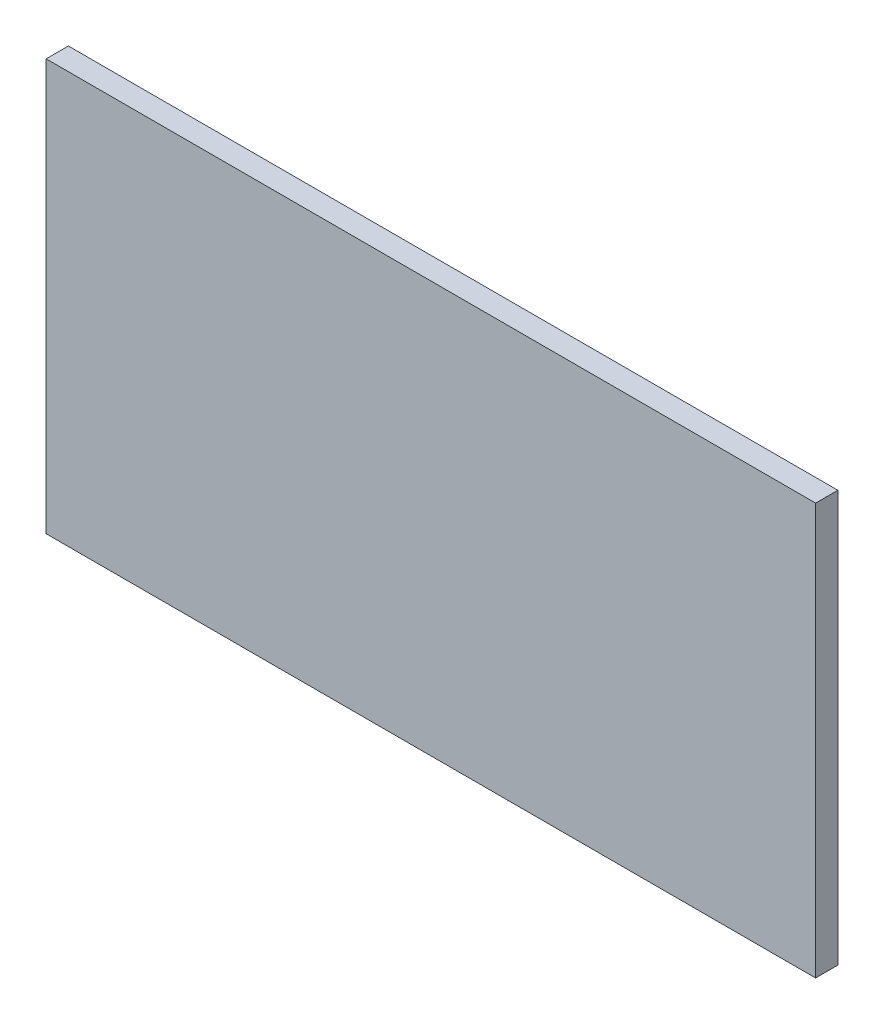
from build123d import *

# Parameters (mm, degrees)
SKETCH1_W           = 623
SKETCH1_H           = 333
BOSS_EXTRUDE1_DEPTH = 18


with BuildPart() as part:
    # Sketch1 → Boss-Extrude1 (new body)
    with BuildSketch(Plane.XY):
        Rectangle(SKETCH1_W, SKETCH1_H)
    extrude(amount=BOSS_EXTRUDE1_DEPTH)


solid = part.part
